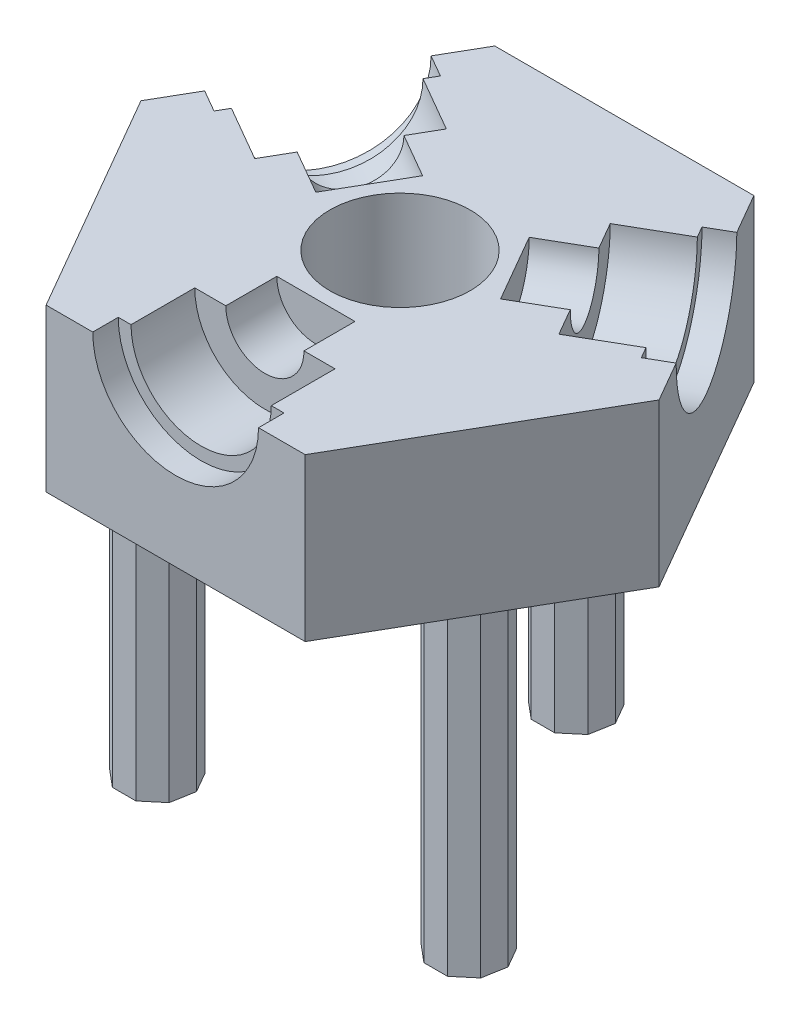
from build123d import *

# Parameters (mm, degrees)
BOSS_EXTRUDE1_DEPTH = 12.7
SKETCH2_R           = 8
SKETCH2_R_2         = 5.5
BOSS_EXTRUDE2_DEPTH = 3.499999906
CIRPATTERN1_COUNT   = 3
SKETCH6_R           = 5.5
CUT_EXTRUDE1_DEPTH  = 17.199999906
BOSS_EXTRUDE3_DEPTH = 25.4


with BuildPart() as part:
    # Sketch1 → Boss-Extrude1 (new body)
    with BuildSketch(Plane(origin=(0, 0, 0), x_dir=(1, 0, 0), z_dir=(0, 1, 0))):
        Polygon((10.16, -17.597636205), (20.32, 0), (10.16, 17.597636205), (-10.16, 17.597636205), (-20.32, 0), (-10.16, -17.597636205), align=None)
    extrude(amount=BOSS_EXTRUDE1_DEPTH)

    # Sketch2 → Boss-Extrude2 (add)
    with BuildSketch(Plane.XZ):
        Circle(SKETCH2_R)
        Circle(SKETCH2_R_2, mode=Mode.SUBTRACT)
    extrude(amount=BOSS_EXTRUDE2_DEPTH)

    # Sketch5 → Cut-Revolve1 (revolve, cut)
    with BuildSketch(Plane(origin=(0, 12.7, 0), x_dir=(1, 0, 0), z_dir=(0, 1, 0))):
        Polygon((0, -17.597636205), (0, -6.597636205), (-3.065310501, -6.597636205), (-3.065310501, -10.597636205), (-5.5, -10.597636205), (-5.5, -15.597636205), (-6.5, -15.597636205), (-6.5, -17.597636205), align=None)
    cut_revolve1 = revolve(axis=Axis((0, 12.7, 17.597636205), (0, 0, -1)), mode=Mode.SUBTRACT)

    # CirPattern1: Cut-Revolve1 ×3 about axis
    cirpattern1_axis = Axis((0, 0, 0), (0, 1, 0))
    for i in range(1, CIRPATTERN1_COUNT):
        add(cut_revolve1.rotate(cirpattern1_axis, i * 360 / CIRPATTERN1_COUNT), mode=Mode.SUBTRACT)

    # Sketch6 → Cut-Extrude1 (cut, through all)
    with BuildSketch(Plane(origin=(0, 12.7, 0), x_dir=(1, 0, 0), z_dir=(0, 1, 0))):
        Circle(SKETCH6_R)
    extrude(amount=-CUT_EXTRUDE1_DEPTH, mode=Mode.SUBTRACT)

    # Sketch8 → Boss-Extrude3 (add)
    with BuildSketch(Plane(origin=(0, 0, 0), x_dir=(1, 0, 0), z_dir=(0, 1, 0))):
        Polygon((-1.915248015, 16.000954519), (-2.83973241, 14.399700576), (-2.518662349, 12.578821777), (-1.102270082, 11.390327548), (0.746698708, 11.390327548), (2.163090976, 12.578821777), (2.484161036, 14.399700576), (1.559676641, 16.000954519), (-0.177785687, 16.63333909), align=None)
        Polygon((14.814348451, -6.342126208), (13.889864056, -4.740872265), (12.152401728, -4.108487694), (10.4149394, -4.740872265), (9.490455005, -6.342126208), (9.811525066, -8.163005007), (11.227917333, -9.351499236), (13.076886123, -9.351499236), (14.49327839, -8.163005007), align=None)
        Polygon((-12.90012529, -9.658841379), (-11.0511565, -9.658841379), (-9.634764233, -8.47034715), (-9.313694172, -6.64946835), (-10.238178567, -5.048214407), (-11.975640895, -4.415829837), (-13.713103223, -5.048214407), (-14.637587618, -6.64946835), (-14.316517557, -8.47034715), align=None)
    extrude(amount=-BOSS_EXTRUDE3_DEPTH)


solid = part.part
